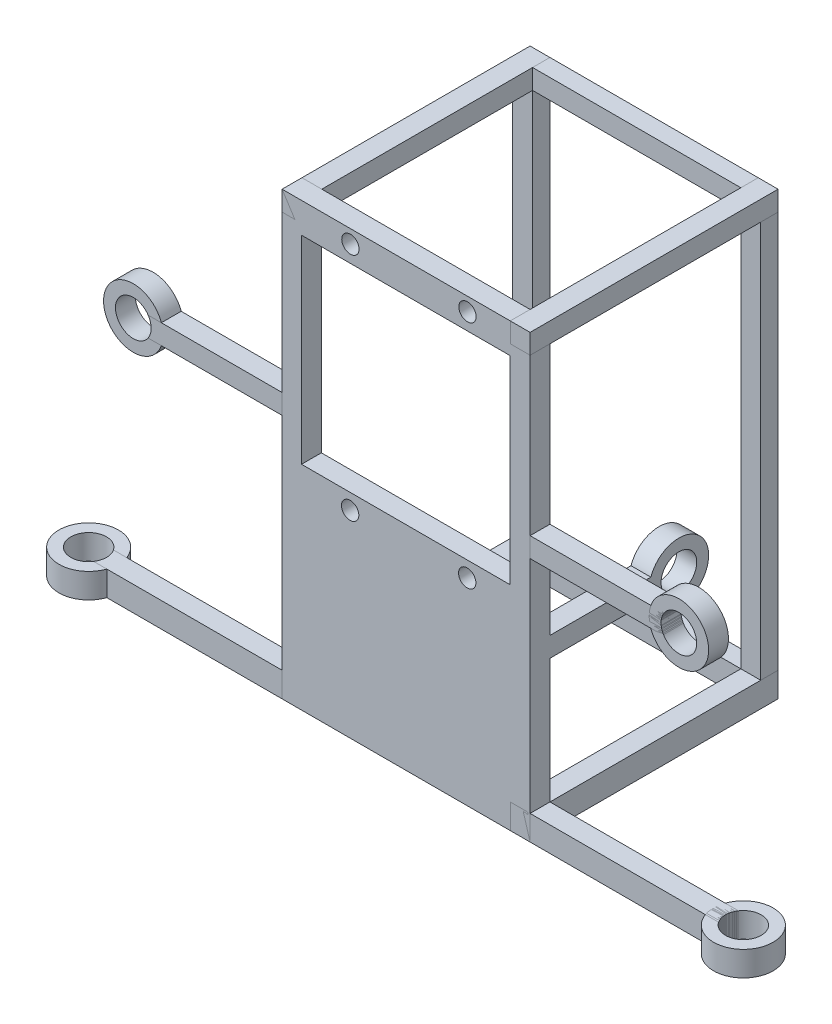
from build123d import *

# Parameters (mm, degrees)
SKETCH114_W             = 3.5
SKETCH114_H             = 80
BOSS_EXTRUDE2_DEPTH     = 4
SKETCH115_W             = 50
SKETCH115_H             = 3.5
BOSS_EXTRUDE3_DEPTH     = 4
SKETCH116_W             = 3.5
SKETCH116_H             = 80
BOSS_EXTRUDE5_DEPTH     = 4
SKETCH117_W             = 50
SKETCH117_H             = 3.5
BOSS_EXTRUDE6_DEPTH     = 5
SKETCH119_W             = 50
SKETCH119_H             = 5
BOSS_EXTRUDE7_DEPTH     = 4
SKETCH119_H_2           = 4
BOSS_EXTRUDE7_2_DEPTH   = 4
SKETCH122_W             = 50
SKETCH122_H             = 4
BOSS_EXTRUDE8_DEPTH     = 4
SKETCH122_H_2           = 5
BOSS_EXTRUDE8_2_DEPTH   = 4
SKETCH134_W             = 50
SKETCH134_H             = 89
BOSS_EXTRUDE18_DEPTH    = 4
SKETCH135_W             = 45
SKETCH135_H             = 4
BOSS_EXTRUDE19_DEPTH    = 5
SKETCH136_W             = 45
SKETCH136_H             = 4
BOSS_EXTRUDE21_DEPTH    = 5
SKETCH137_R             = 6
BOSS_EXTRUDE22_DEPTH    = 5
SKETCH139_R             = 3.6
CUT_EXTRUDE1_DEPTH      = 10
CUT_EXTRUDE1_DEPTH_BACK = 38
SKETCH140_R             = 6
BOSS_EXTRUDE23_DEPTH    = 5
SKETCH143_R             = 3.6
CUT_EXTRUDE2_DEPTH      = 29
CUT_EXTRUDE2_DEPTH_BACK = 17
SKETCH145_W             = 30
SKETCH145_H             = 4
BOSS_EXTRUDE26_DEPTH    = 4
SKETCH146_R             = 6
BOSS_EXTRUDE27_DEPTH    = 4
SKETCH147_R             = 3.6
CUT_EXTRUDE3_DEPTH      = 11
CUT_EXTRUDE3_DEPTH_BACK = 21
SKETCH148_W             = 30
SKETCH148_H             = 4
BOSS_EXTRUDE28_DEPTH    = 4
SKETCH149_R             = 6
BOSS_EXTRUDE29_DEPTH    = 4
SKETCH150_R             = 3.6
CUT_EXTRUDE4_DEPTH      = 12
CUT_EXTRUDE4_DEPTH_BACK = 14
SKETCH156_W             = 42
SKETCH156_H             = 78
CUT_EXTRUDE8_DEPTH      = 4
SKETCH159_W             = 30
SKETCH159_H             = 4
BOSS_EXTRUDE31_DEPTH    = 4
SKETCH160_R             = 6
BOSS_EXTRUDE32_DEPTH    = 4
SKETCH161_R             = 3.6
CUT_EXTRUDE10_DEPTH     = 4
SKETCH162_W             = 42
SKETCH162_H             = 42.813081775
BOSS_EXTRUDE34_DEPTH    = 4
SKETCH164_R             = 1.75
CUT_EXTRUDE12_DEPTH     = 4


with BuildPart() as part:
    # Sketch114 → Boss-Extrude2 (new body)
    with BuildSketch(Plane(origin=(0, 0, 0), x_dir=(0, 0, -1), z_dir=(1, 0, 0))):
        with Locations((1.75, 40)):
            Rectangle(SKETCH114_W, SKETCH114_H)
    extrude(amount=BOSS_EXTRUDE2_DEPTH)


with BuildPart() as body_2:
    # Sketch115 → Boss-Extrude3 (new body)
    with BuildSketch(Plane(origin=(0, 80, 0), x_dir=(1, 0, 0), z_dir=(0, 1, 0))):
        with Locations((25, 1.75)):
            Rectangle(SKETCH115_W, SKETCH115_H)
    extrude(amount=BOSS_EXTRUDE3_DEPTH)


with BuildPart() as body_3:
    # Sketch116 → Boss-Extrude5 (new body)
    with BuildSketch(Plane(origin=(50, 0, 0), x_dir=(0, 0, -1), z_dir=(1, 0, 0))):
        with Locations((1.75, 40)):
            Rectangle(SKETCH116_W, SKETCH116_H)
    extrude(amount=-BOSS_EXTRUDE5_DEPTH)


with BuildPart() as body_4:
    # Sketch117 → Boss-Extrude6 (new body)
    with BuildSketch(Plane.XZ):
        with Locations((25, -1.75)):
            Rectangle(SKETCH117_W, SKETCH117_H)
    extrude(amount=BOSS_EXTRUDE6_DEPTH)


with BuildPart() as body_5:
    # Sketch119 → Boss-Extrude7 (new body)
    with BuildSketch(Plane(origin=(50, 0, 0), x_dir=(0, 0, -1), z_dir=(1, 0, 0))):
        with Locations((-21.5, -2.5)):
            Rectangle(SKETCH119_W, SKETCH119_H)
    extrude(amount=-BOSS_EXTRUDE7_DEPTH)


with BuildPart() as body_6:
    # Sketch119 → Boss-Extrude7 2 (new body)
    with BuildSketch(Plane(origin=(50, 0, 0), x_dir=(0, 0, -1), z_dir=(1, 0, 0))):
        with Locations((-21.5, 82)):
            Rectangle(SKETCH119_W, SKETCH119_H_2)
    extrude(amount=-BOSS_EXTRUDE7_2_DEPTH)


with BuildPart() as body_7:
    # Sketch122 → Boss-Extrude8 (new body)
    with BuildSketch(Plane.ZY):
        with Locations((21.5, 82)):
            Rectangle(SKETCH122_W, SKETCH122_H)
    extrude(amount=-BOSS_EXTRUDE8_DEPTH)


with BuildPart() as body_8:
    # Sketch122 → Boss-Extrude8 2 (new body)
    with BuildSketch(Plane.ZY):
        with Locations((21.5, -2.5)):
            Rectangle(SKETCH122_W, SKETCH122_H_2)
    extrude(amount=-BOSS_EXTRUDE8_2_DEPTH)


with BuildPart() as body_9:
    # Sketch134 → Boss-Extrude18 (new body)
    with BuildSketch(Plane.XY.offset(46.5)):
        with Locations((25, 39.5)):
            Rectangle(SKETCH134_W, SKETCH134_H)
    extrude(amount=-BOSS_EXTRUDE18_DEPTH)


with BuildPart() as body_10:
    # Sketch135 → Boss-Extrude19 (new body)
    with BuildSketch(Plane(origin=(0, -5, 0), x_dir=(-1, 0, 0), z_dir=(0, -1, 0))):
        with Locations((-68.5, -44.5)):
            Rectangle(SKETCH135_W, SKETCH135_H)
    extrude(amount=-BOSS_EXTRUDE19_DEPTH)


with BuildPart() as body_11:
    # Sketch136 → Boss-Extrude21 (new body)
    with BuildSketch(Plane.XZ.offset(5)):
        with Locations((-18.5, 44.5)):
            Rectangle(SKETCH136_W, SKETCH136_H)
    extrude(amount=-BOSS_EXTRUDE21_DEPTH)


with BuildPart() as body_12:
    # Sketch137 → Boss-Extrude22 (new body)
    with BuildSketch(Plane.XZ.offset(5)):
        with Locations((91, 44.5)):
            Circle(SKETCH137_R)
    extrude(amount=-BOSS_EXTRUDE22_DEPTH)


with BuildPart() as cut_extrude1_tool:
    # Sketch139 → Cut-Extrude1 (new body, two sides)
    with BuildSketch(Plane(origin=(0, -5, 0), x_dir=(-1, 0, 0), z_dir=(0, -1, 0))) as cut_extrude1_sk:
        with Locations((-91, -44.5)):
            Circle(SKETCH139_R)
    extrude(amount=CUT_EXTRUDE1_DEPTH)
    extrude(cut_extrude1_sk.sketch, amount=-CUT_EXTRUDE1_DEPTH_BACK)


with BuildPart() as body_10_1:
    add(body_10.part)

    # Cut-Extrude1: cut by cut_extrude1_tool
    add(cut_extrude1_tool.part, mode=Mode.SUBTRACT)


with BuildPart() as body_12_1:
    add(body_12.part)

    # Cut-Extrude1: cut by cut_extrude1_tool
    add(cut_extrude1_tool.part, mode=Mode.SUBTRACT)


with BuildPart() as body_13:
    # Sketch140 → Boss-Extrude23 (new body)
    with BuildSketch(Plane.XZ.offset(5)):
        with Locations((-41, 44.5)):
            Circle(SKETCH140_R)
    extrude(amount=-BOSS_EXTRUDE23_DEPTH)


with BuildPart() as cut_extrude2_tool:
    # Sketch143 → Cut-Extrude2 (new body, two sides)
    with BuildSketch(Plane.XZ.offset(5)) as cut_extrude2_sk:
        with Locations((-41, 44.5)):
            Circle(SKETCH143_R)
    extrude(amount=CUT_EXTRUDE2_DEPTH)
    extrude(cut_extrude2_sk.sketch, amount=-CUT_EXTRUDE2_DEPTH_BACK)


with BuildPart() as body_11_1:
    add(body_11.part)

    # Cut-Extrude2: cut by cut_extrude2_tool
    add(cut_extrude2_tool.part, mode=Mode.SUBTRACT)


with BuildPart() as body_13_1:
    add(body_13.part)

    # Cut-Extrude2: cut by cut_extrude2_tool
    add(cut_extrude2_tool.part, mode=Mode.SUBTRACT)


with BuildPart() as body_14:
    # Sketch145 → Boss-Extrude26 (new body)
    with BuildSketch(Plane(origin=(0, 5, 42.5), x_dir=(-1, 0, 0), z_dir=(0, 0, -1))):
        with Locations((15, 41.5)):
            Rectangle(SKETCH145_W, SKETCH145_H)
    extrude(amount=-BOSS_EXTRUDE26_DEPTH)


with BuildPart() as body_15:
    # Sketch146 → Boss-Extrude27 (new body)
    with BuildSketch(Plane(origin=(0, 5, 46.5), x_dir=(1, 0, 0), z_dir=(0, 0, 1))):
        with Locations((-30, 41.5)):
            Circle(SKETCH146_R)
    extrude(amount=-BOSS_EXTRUDE27_DEPTH)


with BuildPart() as cut_extrude3_tool:
    # Sketch147 → Cut-Extrude3 (new body, two sides)
    with BuildSketch(Plane(origin=(0, 5, 46.5), x_dir=(1, 0, 0), z_dir=(0, 0, 1))) as cut_extrude3_sk:
        with Locations((-30, 41.5)):
            Circle(SKETCH147_R)
    extrude(amount=CUT_EXTRUDE3_DEPTH)
    extrude(cut_extrude3_sk.sketch, amount=-CUT_EXTRUDE3_DEPTH_BACK)


with BuildPart() as body_14_1:
    add(body_14.part)

    # Cut-Extrude3: cut by cut_extrude3_tool
    add(cut_extrude3_tool.part, mode=Mode.SUBTRACT)


with BuildPart() as body_15_1:
    add(body_15.part)

    # Cut-Extrude3: cut by cut_extrude3_tool
    add(cut_extrude3_tool.part, mode=Mode.SUBTRACT)


with BuildPart() as body_16:
    # Sketch148 → Boss-Extrude28 (new body)
    with BuildSketch(Plane(origin=(0, 5, 46.5), x_dir=(1, 0, 0), z_dir=(0, 0, 1))):
        with Locations((65, 41.5)):
            Rectangle(SKETCH148_W, SKETCH148_H)
    extrude(amount=-BOSS_EXTRUDE28_DEPTH)


with BuildPart() as body_17:
    # Sketch149 → Boss-Extrude29 (new body)
    with BuildSketch(Plane(origin=(0, 5, 42.5), x_dir=(-1, 0, 0), z_dir=(0, 0, -1))):
        with Locations((-80, 41.5)):
            Circle(SKETCH149_R)
    extrude(amount=-BOSS_EXTRUDE29_DEPTH)


with BuildPart() as cut_extrude4_tool:
    # Sketch150 → Cut-Extrude4 (new body, two sides)
    with BuildSketch(Plane(origin=(0, 5, 46.5), x_dir=(1, 0, 0), z_dir=(0, 0, 1))) as cut_extrude4_sk:
        with Locations((80, 41.5)):
            Circle(SKETCH150_R)
    extrude(amount=CUT_EXTRUDE4_DEPTH)
    extrude(cut_extrude4_sk.sketch, amount=-CUT_EXTRUDE4_DEPTH_BACK)


with BuildPart() as body_16_1:
    add(body_16.part)

    # Cut-Extrude4: cut by cut_extrude4_tool
    add(cut_extrude4_tool.part, mode=Mode.SUBTRACT)


with BuildPart() as body_17_1:
    add(body_17.part)

    # Cut-Extrude4: cut by cut_extrude4_tool
    add(cut_extrude4_tool.part, mode=Mode.SUBTRACT)


with BuildPart() as cut_extrude8_tool:
    # Sketch156 → Cut-Extrude8 (new body)
    with BuildSketch(Plane.XY.offset(46.5)):
        with Locations((24.914818012, 38.92021053)):
            Rectangle(SKETCH156_W, SKETCH156_H)
    extrude(amount=-CUT_EXTRUDE8_DEPTH)


with BuildPart() as body_8_1:
    add(body_8.part)

    # Cut-Extrude8: cut by cut_extrude8_tool
    add(cut_extrude8_tool.part, mode=Mode.SUBTRACT)


with BuildPart() as body_9_1:
    add(body_9.part)

    # Cut-Extrude8: cut by cut_extrude8_tool
    add(cut_extrude8_tool.part, mode=Mode.SUBTRACT)

    # Sketch159 → Boss-Extrude31 (add)
    with BuildSketch(Plane(origin=(50, 0, 0), x_dir=(0, 0, -1), z_dir=(1, 0, 0))):
        with Locations((-31.5, 27.085014073)):
            Rectangle(SKETCH159_W, SKETCH159_H)
    extrude(amount=-BOSS_EXTRUDE31_DEPTH)

    # Sketch160 → Boss-Extrude32 (add)
    with BuildSketch(Plane.ZY.offset(-46)):
        with Locations((16.5, 27.085014073)):
            Circle(SKETCH160_R)
    extrude(amount=-BOSS_EXTRUDE32_DEPTH)

    # Sketch161 → Cut-Extrude10 (cut)
    with BuildSketch(Plane(origin=(50, 0, 0), x_dir=(0, 0, -1), z_dir=(1, 0, 0))):
        with Locations((-16.5, 27.085014073)):
            Circle(SKETCH161_R)
    extrude(amount=-CUT_EXTRUDE10_DEPTH, mode=Mode.SUBTRACT)

    # Sketch162 → Boss-Extrude34 (add)
    with BuildSketch(Plane.XY.offset(46.5)):
        with Locations((24.914818012, 16.513669643)):
            Rectangle(SKETCH162_W, SKETCH162_H)
    extrude(amount=-BOSS_EXTRUDE34_DEPTH)

    # Sketch164 → Cut-Extrude12 (cut)
    with BuildSketch(Plane(origin=(0, 0, 42.5), x_dir=(-1, 0, 0), z_dir=(0, 0, -1))):
        with Locations((-13.771446852, 81.278551211)):
            Circle(SKETCH164_R)
        with Locations((-37.371446852, 81.278551211)):
            Circle(SKETCH164_R)
        with Locations((-37.321446148, 34.778551211)):
            Circle(SKETCH164_R)
        with Locations((-13.721446148, 34.778551211)):
            Circle(SKETCH164_R)
    extrude(amount=-CUT_EXTRUDE12_DEPTH, mode=Mode.SUBTRACT)


with BuildPart() as body_11_2:
    add(body_11_1.part)

    # Cut-Extrude8: cut by cut_extrude8_tool
    add(cut_extrude8_tool.part, mode=Mode.SUBTRACT)


solid = Compound([part.part, body_2.part, body_3.part, body_4.part, body_5.part, body_6.part, body_7.part, body_10_1.part, body_12_1.part, body_13_1.part, body_14_1.part, body_15_1.part, body_16_1.part, body_17_1.part, body_8_1.part, body_9_1.part, body_11_2.part])
